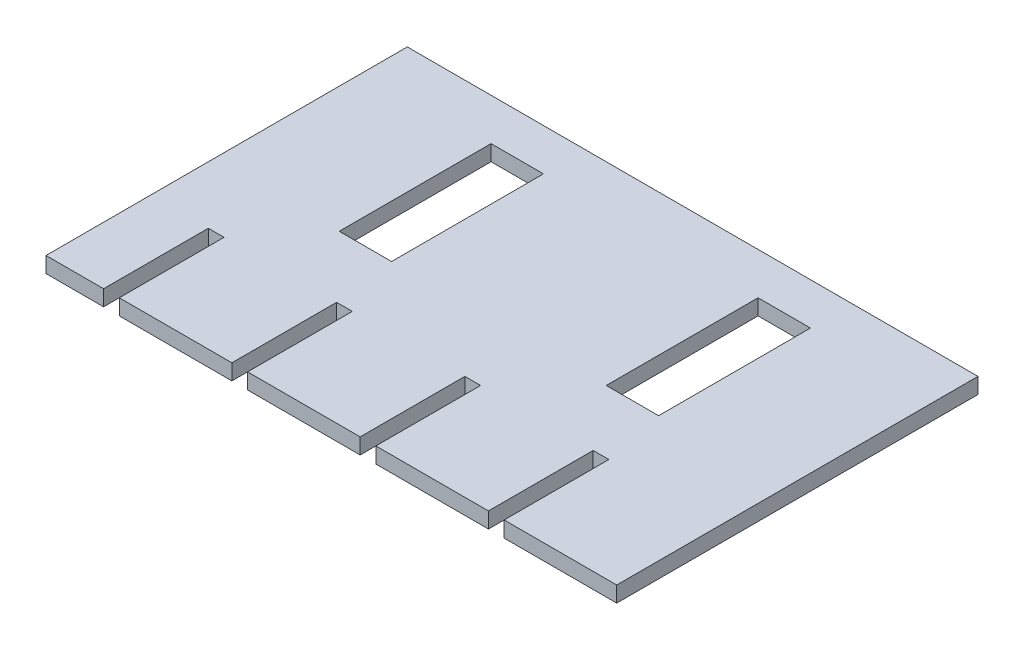
from build123d import *

# Parameters (mm, degrees)
SKETCH1_W           = 54.5
SKETCH1_H           = 34.5
BOSS_EXTRUDE1_DEPTH = 1.5
SKETCH6_W           = 5
SKETCH6_H           = 14.5
CUT_EXTRUDE1_DEPTH  = 2
SKETCH9_W           = 5
SKETCH9_H           = 14.5
CUT_EXTRUDE2_DEPTH  = 2
SKETCH27_W          = 1.5
SKETCH27_H          = 10
CUT_EXTRUDE3_DEPTH  = 2
SKETCH37_W          = 1.5
SKETCH37_H          = 10
CUT_EXTRUDE10_DEPTH = 2
SKETCH39_W          = 1.5
SKETCH39_H          = 10
CUT_EXTRUDE11_DEPTH = 2
SKETCH41_W          = 1.5
SKETCH41_H          = 10
CUT_EXTRUDE12_DEPTH = 2


with BuildPart() as part:
    # Sketch1 → Boss-Extrude1 (new body)
    with BuildSketch(Plane(origin=(0, 0, 0), x_dir=(1, 0, 0), z_dir=(0, 1, 0))):
        Rectangle(SKETCH1_W, SKETCH1_H)
    extrude(amount=BOSS_EXTRUDE1_DEPTH)

    # Sketch6 → Cut-Extrude1 (cut)
    with BuildSketch(Plane(origin=(0, 1.5, 0), x_dir=(1, 0, 0), z_dir=(0, 1, 0))):
        with Locations((-12.75, 6)):
            Rectangle(SKETCH6_W, SKETCH6_H)
    extrude(amount=-CUT_EXTRUDE1_DEPTH, mode=Mode.SUBTRACT)

    # Sketch9 → Cut-Extrude2 (cut)
    with BuildSketch(Plane(origin=(0, 1.5, 0), x_dir=(1, 0, 0), z_dir=(0, 1, 0))):
        with Locations((12.75, 6)):
            Rectangle(SKETCH9_W, SKETCH9_H)
    extrude(amount=-CUT_EXTRUDE2_DEPTH, mode=Mode.SUBTRACT)

    # Sketch27 → Cut-Extrude3 (cut)
    with BuildSketch(Plane(origin=(0, 1.5, 0), x_dir=(1, 0, 0), z_dir=(0, 1, 0))):
        with Locations((-21, -12.25)):
            Rectangle(SKETCH27_W, SKETCH27_H)
    extrude(amount=-CUT_EXTRUDE3_DEPTH, mode=Mode.SUBTRACT)

    # Sketch37 → Cut-Extrude10 (cut)
    with BuildSketch(Plane(origin=(0, 1.5, 0), x_dir=(1, 0, 0), z_dir=(0, 1, 0))):
        with Locations((3.5, -12.25)):
            Rectangle(SKETCH37_W, SKETCH37_H)
    extrude(amount=-CUT_EXTRUDE10_DEPTH, mode=Mode.SUBTRACT)

    # Sketch39 → Cut-Extrude11 (cut)
    with BuildSketch(Plane(origin=(0, 1.5, 0), x_dir=(1, 0, 0), z_dir=(0, 1, 0))):
        with Locations((-8.75, -12.25)):
            Rectangle(SKETCH39_W, SKETCH39_H)
    extrude(amount=-CUT_EXTRUDE11_DEPTH, mode=Mode.SUBTRACT)

    # Sketch41 → Cut-Extrude12 (cut)
    with BuildSketch(Plane(origin=(0, 1.5, 0), x_dir=(1, 0, 0), z_dir=(0, 1, 0))):
        with Locations((15.75, -12.25)):
            Rectangle(SKETCH41_W, SKETCH41_H)
    extrude(amount=-CUT_EXTRUDE12_DEPTH, mode=Mode.SUBTRACT)


solid = part.part
